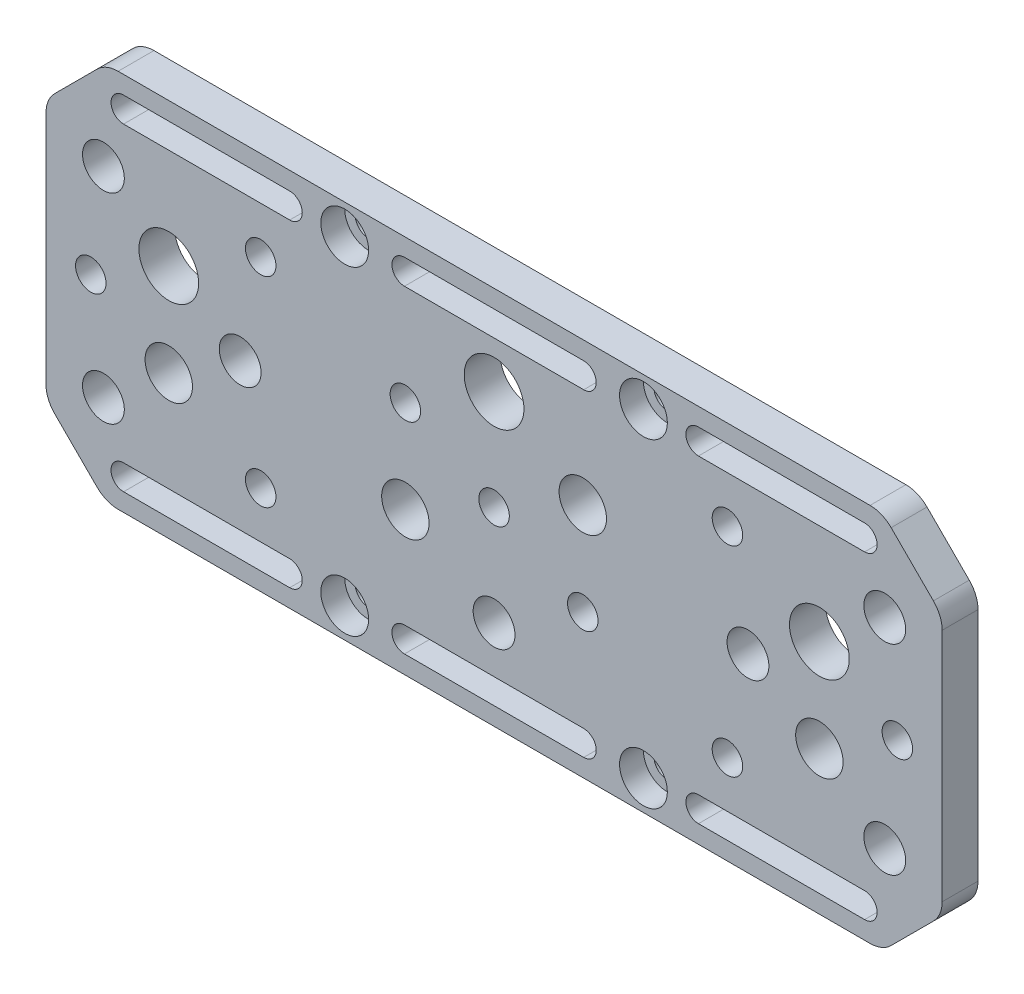
from build123d import *

# Parameters (mm, degrees)
EXTRUDE_2_DEPTH             = 6
HOLE_WIZARD_M41_D           = 4.5
HOLE_WIZARD_M41_CBORE_D     = 8
HOLE_WIZARD_M41_CBORE_DEPTH = 4
SKETCH_13_R                 = 5
SKETCH_13_R_2               = 3.5
CUT_EXTRUDE_1_DEPTH         = 7
FILLET_1_R                  = 5
HOLE_WIZARD_1_4_202_D       = 5.1054
HOLE_WIZARD_3_8_161_D       = 7.9375
HOLE_WIZARD_1_4_203_D       = 5.1054
HOLE_WIZARD_3_8_163_D       = 7.9375


with BuildPart() as part:
    # Эскиз5 → Бобышка-Вытянуть2 (new body)
    with BuildSketch(Plane.XY):
        Polygon((-75, 21.75), (-65, 31.75), (65, 31.75), (75, 21.75), (75, -21.75), (65, -31.75), (-65, -31.75), (-75, -21.75), align=None)
    extrude(amount=EXTRUDE_2_DEPTH)

    # Цековка для винта с внутренним шестигранником M41 (through all)
    with Locations(Plane.XY.offset(6)):
        with Locations((-25, 26.75), (-25, -26.75), (25, -26.75), (25, 26.75)):
            CounterBoreHole(HOLE_WIZARD_M41_D / 2, HOLE_WIZARD_M41_CBORE_D / 2, HOLE_WIZARD_M41_CBORE_DEPTH)

    # Эскиз13 → Вырез-Вытянуть1 (cut, through all)
    with BuildSketch(Plane.XY.offset(6)):
        with Locations((-54.451239655, 7.75)):
            Circle(SKETCH_13_R)
        with Locations((-65.388741386, 16.75)):
            Circle(SKETCH_13_R_2)
        with Locations((-65.388741386, -16.75)):
            Circle(SKETCH_13_R_2)
        with Locations((65.388741386, -16.75)):
            Circle(SKETCH_13_R_2)
        with Locations((54.451239655, 7.75)):
            Circle(SKETCH_13_R)
        with Locations((65.388741386, 16.75)):
            Circle(SKETCH_13_R_2)
        with Locations((0, -16.75)):
            Circle(SKETCH_13_R_2)
        with Locations((-42.5, 0)):
            Circle(SKETCH_13_R_2)
        with Locations((0, 16.75)):
            Circle(SKETCH_13_R)
        with Locations((42.5, 0)):
            Circle(SKETCH_13_R_2)
        with BuildLine():
            Line((-34.207920637, 24.55), (-62.016348651, 24.55))
            ThreePointArc((-62.016348651, 24.55), (-64.116348651, 26.65), (-62.016348651, 28.75))
            Line((-62.016348651, 28.75), (-34.207920637, 28.75))
            ThreePointArc((-34.207920637, 28.75), (-32.107920637, 26.65), (-34.207920637, 24.55))
        make_face()
        with BuildLine():
            Line((34.207920637, 24.55), (62.016348651, 24.55))
            ThreePointArc((62.016348651, 24.55), (64.116348651, 26.65), (62.016348651, 28.75))
            Line((62.016348651, 28.75), (34.207920637, 28.75))
            ThreePointArc((34.207920637, 28.75), (32.107920637, 26.65), (34.207920637, 24.55))
        make_face()
        with BuildLine():
            Line((-34.207920637, -24.55), (-62.016348651, -24.55))
            ThreePointArc((-62.016348651, -24.55), (-64.116348651, -26.65), (-62.016348651, -28.75))
            Line((-62.016348651, -28.75), (-34.207920637, -28.75))
            ThreePointArc((-34.207920637, -28.75), (-32.107920637, -26.65), (-34.207920637, -24.55))
        make_face()
        with BuildLine():
            Line((34.207920637, -24.55), (62.016348651, -24.55))
            ThreePointArc((62.016348651, -24.55), (64.116348651, -26.65), (62.016348651, -28.75))
            Line((62.016348651, -28.75), (34.207920637, -28.75))
            ThreePointArc((34.207920637, -28.75), (32.107920637, -26.65), (34.207920637, -24.55))
        make_face()
        with BuildLine():
            Line((-15, 28.75), (15, 28.75))
            ThreePointArc((15, 28.75), (17.1, 26.65), (15, 24.55))
            Line((15, 24.55), (-15, 24.55))
            ThreePointArc((-15, 24.55), (-17.1, 26.65), (-15, 28.75))
        make_face()
        with BuildLine():
            Line((-15, -28.75), (15, -28.75))
            ThreePointArc((15, -28.75), (17.1, -26.65), (15, -24.55))
            Line((15, -24.55), (-15, -24.55))
            ThreePointArc((-15, -24.55), (-17.1, -26.65), (-15, -28.75))
        make_face()
    extrude(amount=-CUT_EXTRUDE_1_DEPTH, mode=Mode.SUBTRACT)

    # Скругление1
    fillet_1_edges = [part.edges().sort_by_distance(p)[0] for p in [
        (65, 31.75, 3),
        (75, 21.75, 3),
        (75, -21.75, 3),
        (65, -31.75, 3),
        (-65, -31.75, 3),
        (-75, -21.75, 3),
        (-75, 21.75, 3),
        (-65, 31.75, 3),
    ]]
    fillet(fillet_1_edges, radius=FILLET_1_R)

    # Отверстие обработанное метчиком 1/4-202 (through all)
    with Locations(Plane.XY.offset(6)):
        with Locations((-67.5, 0), (-39.060049923, 16.75), (-39.060049923, -16.75), (39.060049923, 16.75), (39.060049923, -16.75), (67.5, 0)):
            Hole(HOLE_WIZARD_1_4_202_D / 2)

    # Отверстие обработанное метчиком 3/8-161 (through all)
    with Locations(Plane.XY.offset(6)):
        with Locations((-54.451239655, -7.75), (54.451239655, -7.75)):
            Hole(HOLE_WIZARD_3_8_161_D / 2)

    # Отверстие обработанное метчиком 1/4-203 (through all)
    with Locations(Plane.XY.offset(6)):
        with Locations((0, 0), (-14.849242405, 7.75), (14.849242405, -7.75)):
            Hole(HOLE_WIZARD_1_4_203_D / 2)

    # Отверстие обработанное метчиком 3/8-163 (through all)
    with Locations(Plane.XY.offset(6)):
        with Locations((-14.849242405, -7.75), (14.849242405, 7.75)):
            Hole(HOLE_WIZARD_3_8_163_D / 2)


solid = part.part
